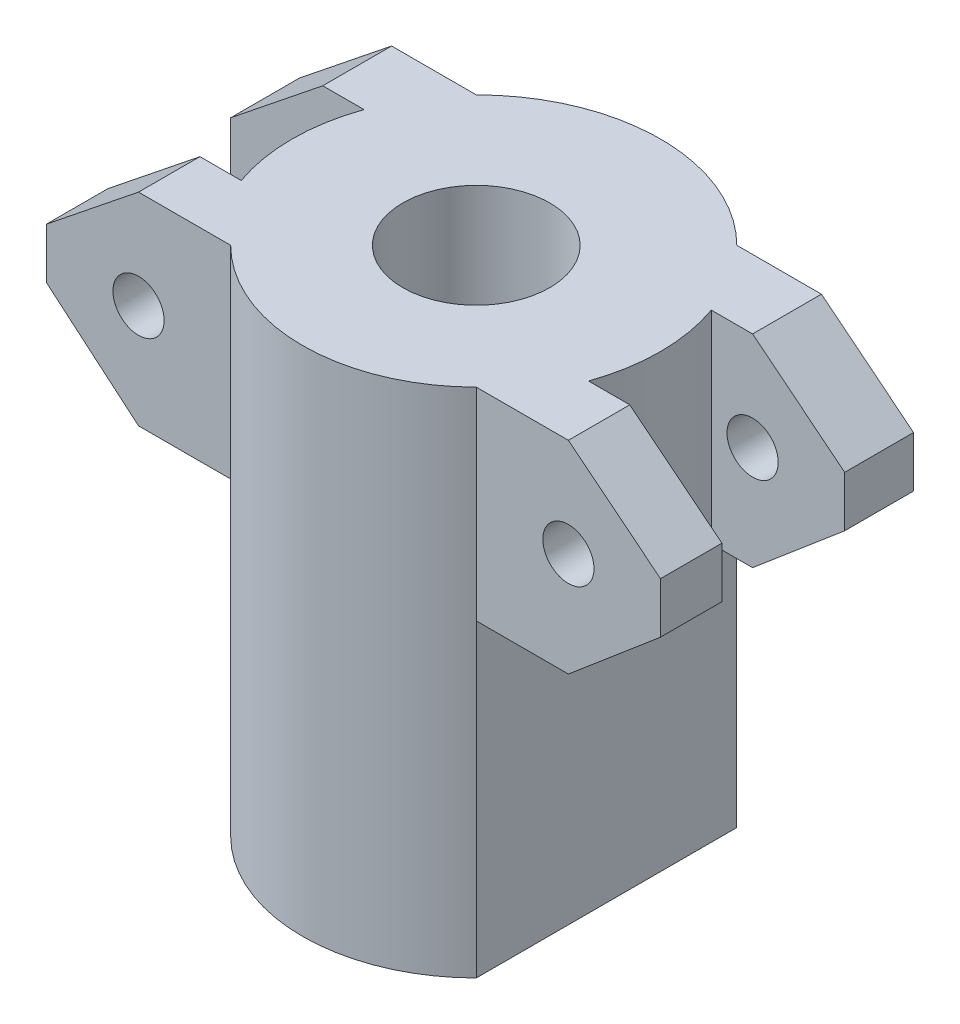
from build123d import *

# Parameters (mm, degrees)
SKETCH_1_R               = 7.179803271
EXTRUDE_1_DEPTH          = 50
SKETCH_3_OUTSIDE_W       = 79.114
SKETCH_3_OUTSIDE_H       = 69.114
SKETCH_3_OUTSIDE_R       = 2.5
CUT_EXTRUDE_1_DEPTH      = 17.970562748
CUT_EXTRUDE_1_DEPTH_BACK = 19


with BuildPart() as part:
    # Эскиз1 → Бобышка-Вытянуть1 (new body)
    with BuildSketch(Plane(origin=(0, 0, 0), x_dir=(1, 0, 0), z_dir=(0, 1, 0))):
        with BuildLine():
            Line((-30, 12.727922061), (-30, 6))
            Line((-30, 6), (-16.963843494, 6))
            ThreePointArc((-16.963843494, 6), (-17.993665165, 0), (-16.963843494, -6))
            Line((-16.963843494, -6), (-30, -6))
            Line((-30, -6), (-30, -12))
            Line((-30, -12), (-12, -12))
            ThreePointArc((-12, -12), (0, -16.970562748), (12, -12))
            Line((12, -12), (30, -12))
            Line((30, -12), (30, -6))
            Line((30, -6), (16.963843494, -6))
            ThreePointArc((16.963843494, -6), (17.993665165, 0), (16.963843494, 6))
            Line((16.963843494, 6), (30, 6))
            Line((30, 6), (30, 12.727922061))
            Line((30, 12.727922061), (12.727922061, 12.727922061))
            ThreePointArc((12.727922061, 12.727922061), (0, 18), (-12.727922061, 12.727922061))
            Line((-12.727922061, 12.727922061), (-30, 12.727922061))
        make_face()
        Circle(SKETCH_1_R, mode=Mode.SUBTRACT)
    extrude(amount=EXTRUDE_1_DEPTH)

    # Эскиз3 outside → Вырез-Вытянуть1 (cut, two sides)
    with BuildSketch(Plane.XY) as cut_extrude_1_sk:
        with Locations((0, 25)):
            Rectangle(SKETCH_3_OUTSIDE_W, SKETCH_3_OUTSIDE_H)
        Polygon((21, 50), (-21, 50), (-30, 42.791951294), (-30, 37.841695699), (-21, 30.220907479), (-12, 30.220907479), (-12, 0), (12, 0), (12, 30.220907479), (21, 30.220907479), (30, 37.841695699), (30, 42.791951294), align=None, mode=Mode.SUBTRACT)
        with Locations((-21, 40.381958439)):
            Circle(SKETCH_3_OUTSIDE_R)
        with Locations((21, 40.381958439)):
            Circle(SKETCH_3_OUTSIDE_R)
    extrude(amount=CUT_EXTRUDE_1_DEPTH, mode=Mode.SUBTRACT)
    extrude(cut_extrude_1_sk.sketch, amount=-CUT_EXTRUDE_1_DEPTH_BACK, mode=Mode.SUBTRACT)


solid = part.part
